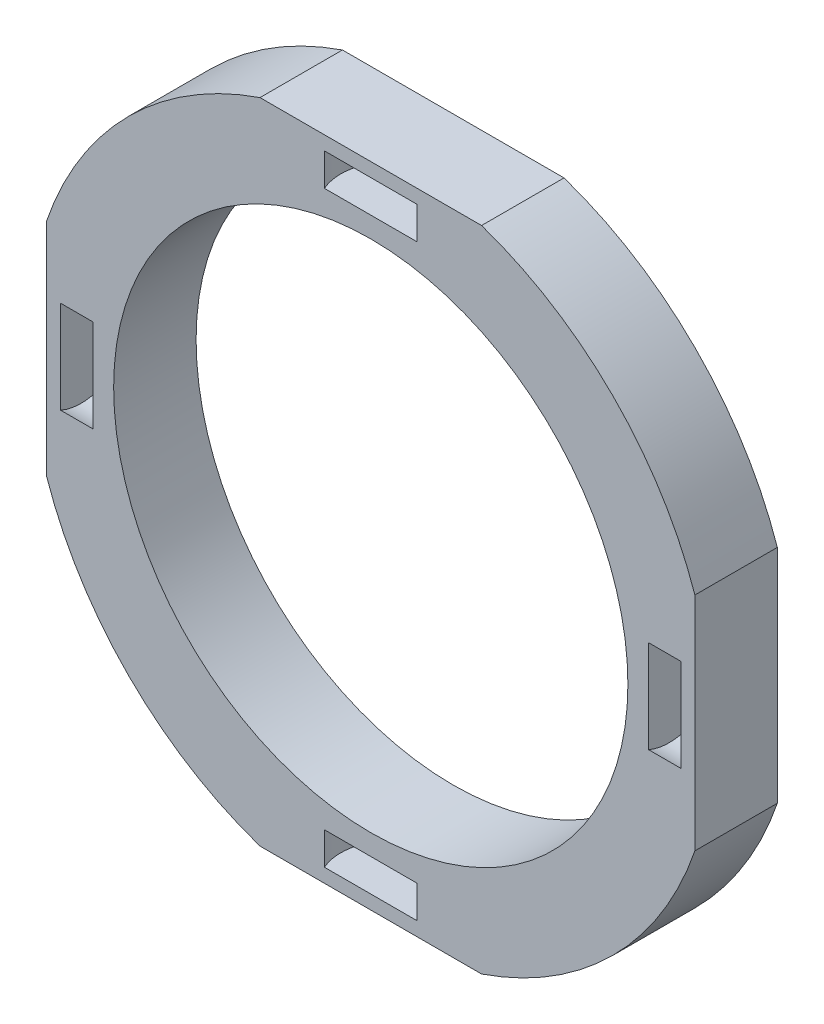
from build123d import *

# Parameters (mm, degrees)
SKETCH1_R                = 12.6746
BOSS_EXTRUDE1_DEPTH      = 1.016
BOSS_EXTRUDE1_DEPTH_BACK = 3.048
SKETCH3_W                = 1.6002
SKETCH3_H                = 2.499999953
CIRPATTERN1_COUNT        = 4


with BuildPart() as part:
    # Sketch1 → Boss-Extrude1 (new body, two sides)
    with BuildSketch(Plane.XY) as boss_extrude1_sk:
        with BuildLine():
            ThreePointArc((-5.461088217, 15.9766), (-11.938911845, 11.938911845), (-15.9766, 5.461088217))
            Line((-15.9766, 5.461088217), (-15.9766, -5.461088217))
            ThreePointArc((-15.9766, -5.461088217), (-11.938911845, -11.938911845), (-5.461088217, -15.9766))
            Line((-5.461088217, -15.9766), (5.461088217, -15.9766))
            ThreePointArc((5.461088217, -15.9766), (11.938911845, -11.938911845), (15.9766, -5.461088217))
            Line((15.9766, -5.461088217), (15.9766, 5.461088217))
            ThreePointArc((15.9766, 5.461088217), (11.938911845, 11.938911845), (5.461088217, 15.9766))
            Line((5.461088217, 15.9766), (-5.461088217, 15.9766))
        make_face()
        Circle(SKETCH1_R, mode=Mode.SUBTRACT)
    extrude(amount=BOSS_EXTRUDE1_DEPTH)
    extrude(boss_extrude1_sk.sketch, amount=-BOSS_EXTRUDE1_DEPTH_BACK)

    # Sketch3 → Cut-Revolve2 (revolve, cut)
    with BuildSketch(Plane.XY):
        with Locations((-14.4907, -1.249999977)):
            Rectangle(SKETCH3_W, SKETCH3_H)
    cut_revolve2 = revolve(axis=Axis((-13.6906, 0, 0), (-1, 0, 0)), mode=Mode.SUBTRACT)

    # CirPattern1: Cut-Revolve2 ×4 about axis
    cirpattern1_axis = Axis((0, 0, 0), (0, 0, 1))
    for i in range(1, CIRPATTERN1_COUNT):
        add(cut_revolve2.rotate(cirpattern1_axis, i * 360 / CIRPATTERN1_COUNT), mode=Mode.SUBTRACT)


solid = part.part
